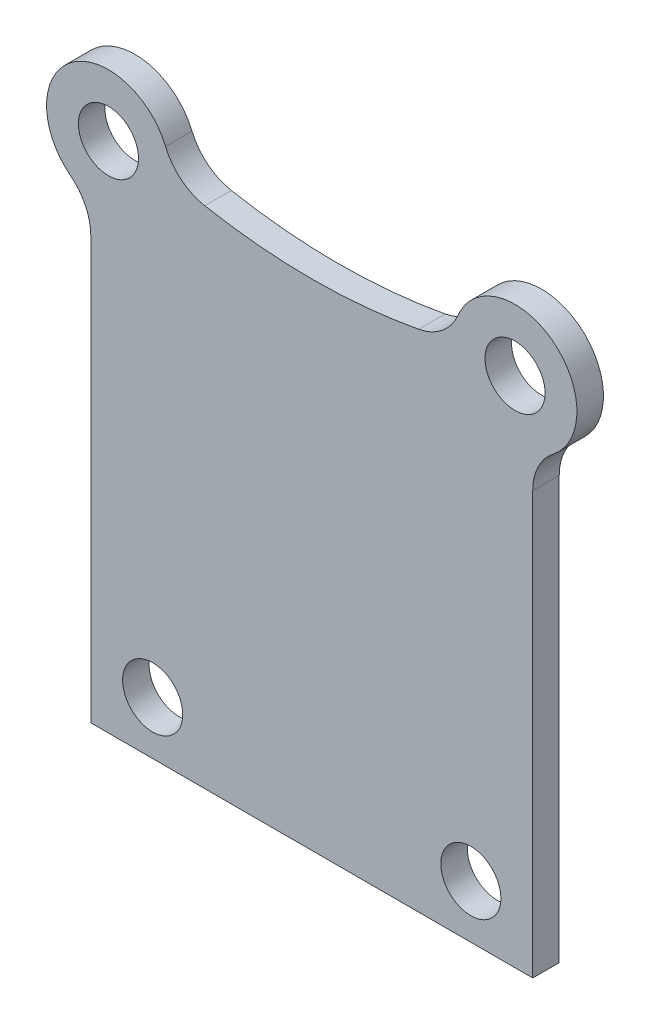
from build123d import *

# Parameters (mm, degrees)
EXTRUDE_1_DEPTH       = 1.5
HOLE_WIZARD_M31_D     = 3.4
HOLE_WIZARD_M31_DEPTH = 1.5


with BuildPart() as part:
    # Эскиз1 → Бобышка-Вытянуть1 (new body)
    with BuildSketch(Plane.XY):
        with BuildLine():
            Line((-12.5, -56.123475383), (-12.5, -80))
            Line((-12.5, -80), (12.5, -80))
            Line((12.5, -80), (12.5, -56.123475383))
            ThreePointArc((12.5, -56.123475383), (12.803848897, -54.807888354), (13.653846154, -53.758794437))
            ThreePointArc((13.653846154, -53.758794437), (13.623122203, -48.217491759), (8.270384407, -49.651080759))
            ThreePointArc((8.270384407, -49.651080759), (7.388025887, -50.827983152), (6.0522893, -51.4439893))
            ThreePointArc((6.0522893, -51.4439893), (0, -52.003676272), (-6.0522893, -51.4439893))
            ThreePointArc((-6.0522893, -51.4439893), (-7.388025887, -50.827983152), (-8.270384407, -49.651080759))
            ThreePointArc((-8.270384407, -49.651080759), (-13.623122203, -48.217491759), (-13.653846154, -53.758794437))
            ThreePointArc((-13.653846154, -53.758794437), (-12.803848897, -54.807888354), (-12.5, -56.123475383))
        make_face()
    extrude(amount=-EXTRUDE_1_DEPTH)

    # Отверстие с зазором M31
    with Locations(Plane.XY):
        with Locations((11.5, -51), (-11.5, -51), (9, -77), (-9, -77)):
            Hole(HOLE_WIZARD_M31_D / 2, depth=HOLE_WIZARD_M31_DEPTH)


solid = part.part
